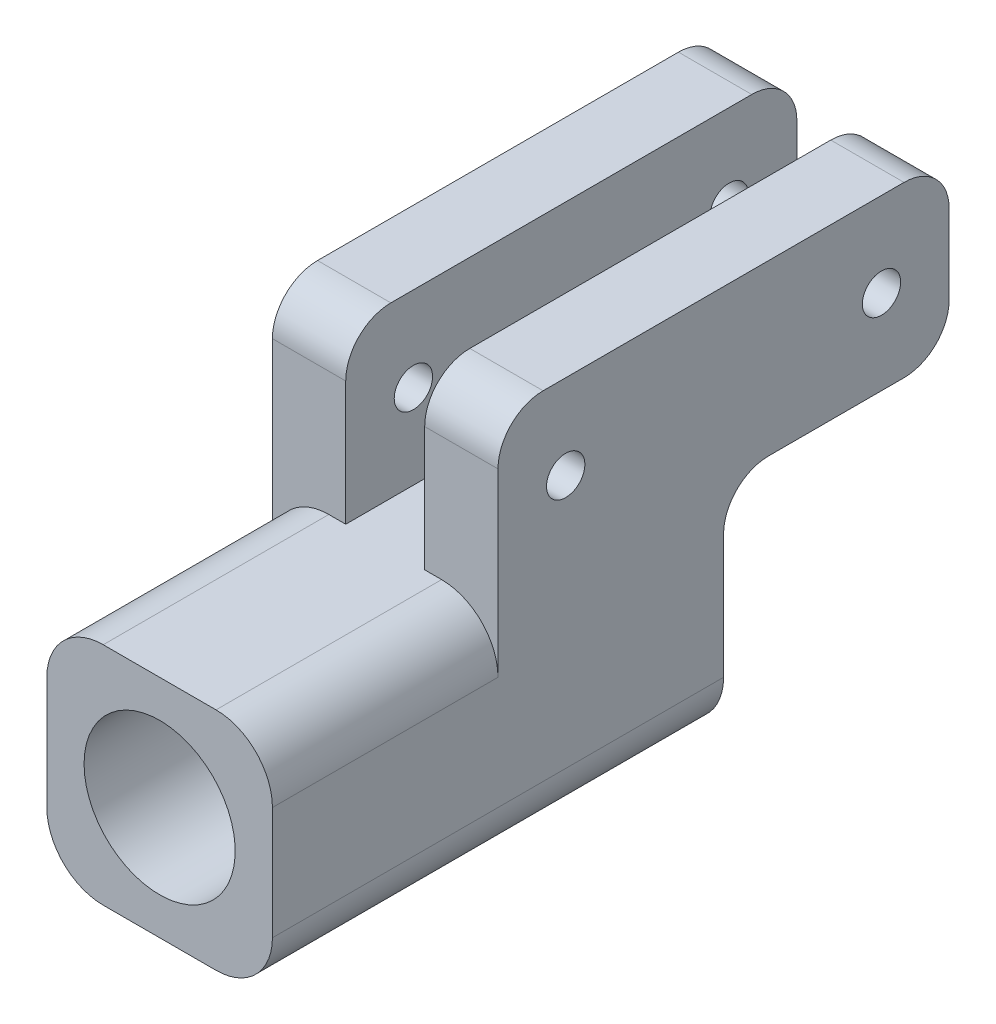
from build123d import *

# Parameters (mm, degrees)
CROQUIS1_W              = 20
CROQUIS1_H              = 40
SALIENTE_EXTRUIR1_DEPTH = 10
CROQUIS5_R              = 6.7
CORTAR_EXTRUIR1_DEPTH   = 40
CROQUIS6_W              = 40
CROQUIS6_H              = 15
SALIENTE_EXTRUIR2_DEPTH = 10
CROQUIS7_W              = 7
CROQUIS7_H              = 40
CORTAR_EXTRUIR2_DEPTH   = 15
CROQUIS8_R              = 1.7
CORTAR_EXTRUIR3_DEPTH   = 20
REDONDEO1_R             = 4
REDONDEO2_R             = 5


with BuildPart() as part:
    # Croquis1 → Saliente-Extruir1 (new body, symmetric)
    with BuildSketch(Plane(origin=(0, 0, 0), x_dir=(1, 0, 0), z_dir=(0, 1, 0))):
        Rectangle(CROQUIS1_W, CROQUIS1_H)
    extrude(amount=SALIENTE_EXTRUIR1_DEPTH, both=True)

    # Croquis5 → Cortar-Extruir1 (cut)
    with BuildSketch(Plane(origin=(0, 0, -20), x_dir=(-1, 0, 0), z_dir=(0, 0, -1))):
        Circle(CROQUIS5_R)
    extrude(amount=-CORTAR_EXTRUIR1_DEPTH, mode=Mode.SUBTRACT)

    # Croquis6 → Saliente-Extruir2 (add, symmetric)
    with BuildSketch(Plane(origin=(0, 0, 0), x_dir=(0, 0, -1), z_dir=(1, 0, 0))):
        with Locations((20, 17.5)):
            Rectangle(CROQUIS6_W, CROQUIS6_H)
    extrude(amount=SALIENTE_EXTRUIR2_DEPTH, both=True)

    # Croquis7 → Cortar-Extruir2 (cut)
    with BuildSketch(Plane(origin=(0, 25, 0), x_dir=(1, 0, 0), z_dir=(0, 1, 0))):
        with Locations((0, 20)):
            Rectangle(CROQUIS7_W, CROQUIS7_H)
    extrude(amount=-CORTAR_EXTRUIR2_DEPTH, mode=Mode.SUBTRACT)

    # Croquis8 → Cortar-Extruir3 (cut)
    with BuildSketch(Plane(origin=(10, 0, 0), x_dir=(0, 0, -1), z_dir=(1, 0, 0))):
        with Locations((6, 17.5)):
            Circle(CROQUIS8_R)
        with Locations((34, 17.5)):
            Circle(CROQUIS8_R)
    extrude(amount=-CORTAR_EXTRUIR3_DEPTH, mode=Mode.SUBTRACT)

    # Redondeo1
    redondeo1_edges = [part.edges().sort_by_distance(p)[0] for p in [
        (6.75, 10, -40),
        (6.75, 25, -40),
        (6.75, 25, 0),
        (-6.75, 25, 0),
        (-6.75, 25, -40),
        (-6.75, 10, -40),
        (-6.75, 10, -20),
        (6.75, 10, -20),
    ]]
    fillet(redondeo1_edges, radius=REDONDEO1_R)

    # Redondeo2
    redondeo2_edges = [part.edges().sort_by_distance(p)[0] for p in [
        (-10, 10, 10),
        (10, 10, 10),
        (-10, -10, 0),
        (10, -10, 0),
    ]]
    fillet(redondeo2_edges, radius=REDONDEO2_R)


solid = part.part
